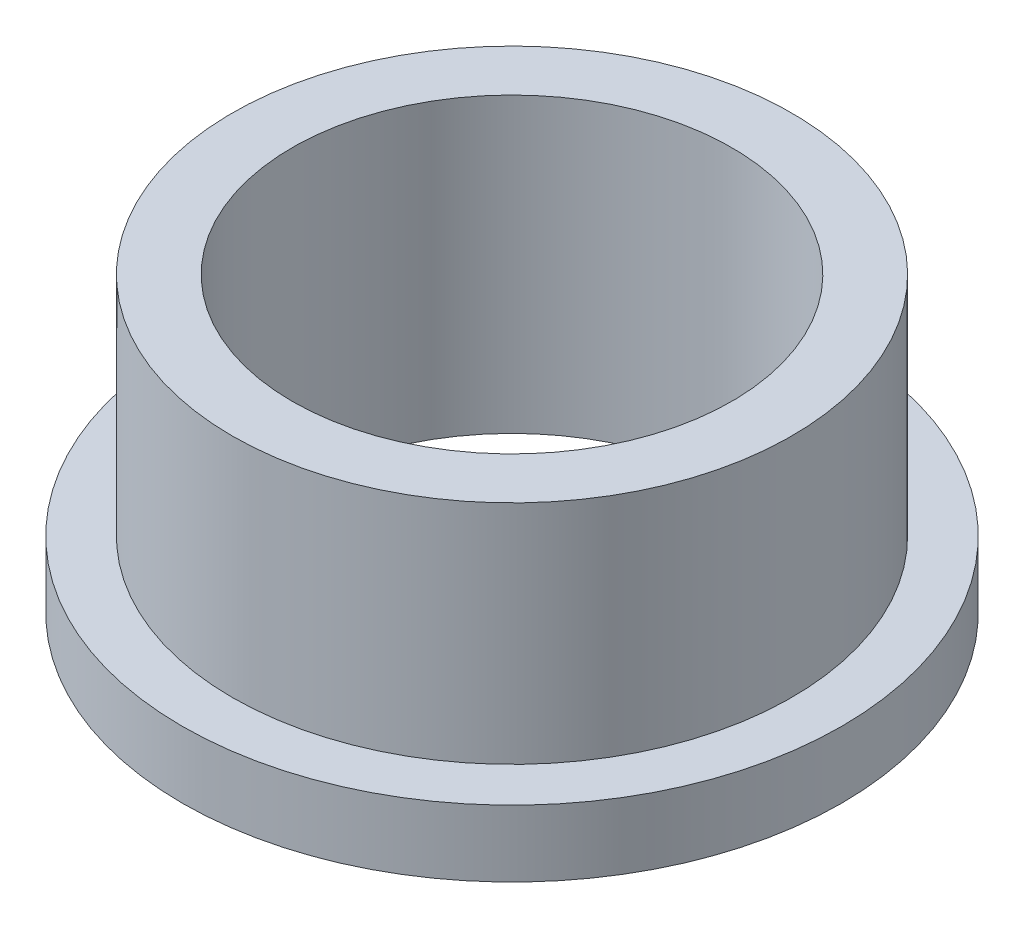
from build123d import *


with BuildPart() as part:
    # Sketch1 → Revolve1 (revolve)
    with BuildSketch(Plane.XY):
        Polygon((-4.95, 0), (-3.3, 0), (-3.3, 4.4), (-4.2, 4.4), (-4.2, 1), (-4.95, 1), align=None)
    revolve(axis=Axis((0, 4.62, 0), (0, -1, 0)))


solid = part.part
